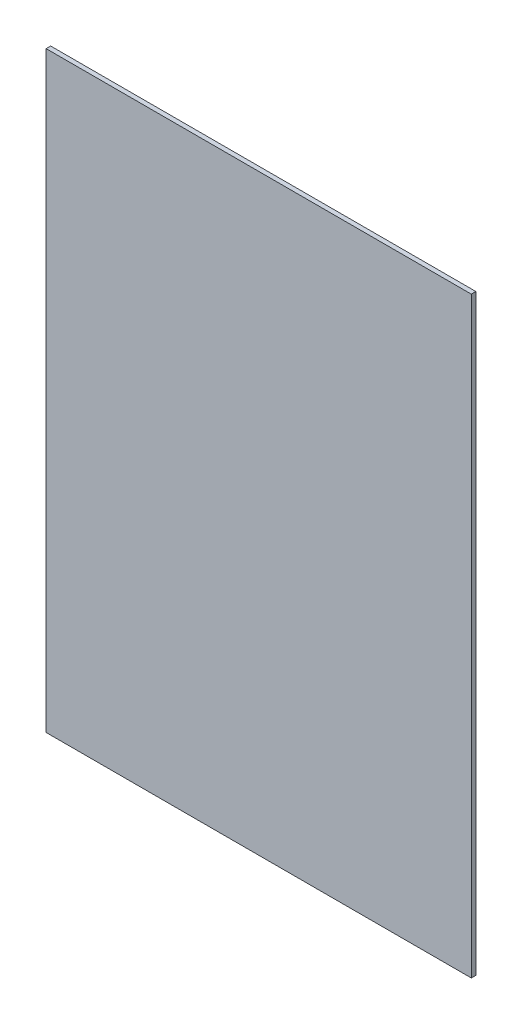
from build123d import *

# Parameters (mm, degrees)
SKETCH1_W           = 28
SKETCH1_H           = 39
BOSS_EXTRUDE1_DEPTH = 0.3


with BuildPart() as part:
    # Sketch1 → Boss-Extrude1 (new body)
    with BuildSketch(Plane.XY):
        with Locations((14, 19.5)):
            Rectangle(SKETCH1_W, SKETCH1_H)
    extrude(amount=BOSS_EXTRUDE1_DEPTH)


solid = part.part
